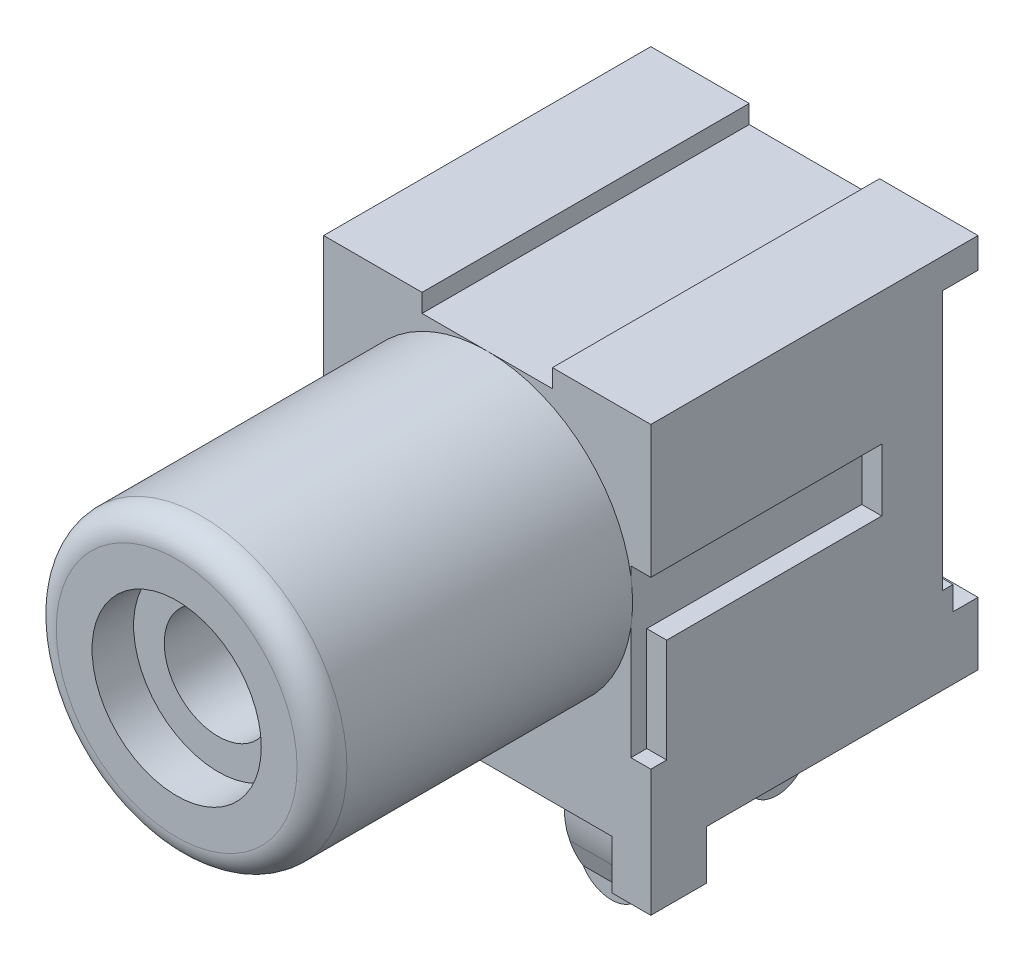
from build123d import *

# Parameters (mm, degrees)
SKETCH1_W          = 10.0076
SKETCH1_H          = 13.0048
EXTRUDE1_DEPTH     = 10.0076
SKETCH2_R          = 4.445
EXTRUDE2_DEPTH     = 9.4996
FILLET1_R          = 0.762
SKETCH3_R          = 1.64973
CUT_EXTRUDE1_DEPTH = 9.4996
CUT_EXTRUDE2_DEPTH = 0.6096
SKETCH5_W          = 1.082217623
SKETCH5_H          = 7.941923042
CUT_EXTRUDE3_DEPTH = 11.0076
SKETCH6_W          = 7.62
SKETCH6_H          = 1.4986
CUT_EXTRUDE4_DEPTH = 11.0076
SKETCH7_R          = 2.588003294
CUT_EXTRUDE5_DEPTH = 1.27
SKETCH8_W          = 3.9878
SKETCH8_H          = 0.5588
CUT_EXTRUDE6_DEPTH = 11.0076
SKETCH10_W         = 8.302680101
SKETCH10_H         = 1.4986
CUT_EXTRUDE8_DEPTH = 11.0076
SKETCH11_W         = 0.763867388
SKETCH11_H         = 0.721519404
CUT_EXTRUDE9_DEPTH = 11.0076
SKETCH12_W         = 2.0066
SKETCH12_H         = 0.381
FILLET2_R          = 0.9906
EXTRUDE3_DEPTH     = 0.254


with BuildPart() as part:
    # Sketch1 → Extrude1 (new body)
    with BuildSketch(Plane.XY):
        with Locations((0, 6.5024)):
            Rectangle(SKETCH1_W, SKETCH1_H)
    extrude(amount=-EXTRUDE1_DEPTH)

    # Sketch2 → Extrude2 (add)
    with BuildSketch(Plane.XY):
        with Locations((0, 8.001)):
            Circle(SKETCH2_R)
    extrude(amount=EXTRUDE2_DEPTH)

    # Fillet1
    fillet1_edges = [part.edges().sort_by_distance(p)[0] for p in [
        (-4.445, 8.001, 9.4996),
    ]]
    fillet(fillet1_edges, radius=FILLET1_R)

    # Sketch3 → Cut-Extrude1 (cut)
    with BuildSketch(Plane.XY.offset(9.4996)):
        with Locations((0, 8.001)):
            Circle(SKETCH3_R)
    extrude(amount=-CUT_EXTRUDE1_DEPTH, mode=Mode.SUBTRACT)

    # Sketch4 → Cut-Extrude2 (cut)
    with BuildSketch(Plane(origin=(5.0038, 0, 0), x_dir=(0, 0, -1), z_dir=(1, 0, 0))):
        Polygon((0, 8.9535), (7.063951239, 8.9535), (7.063951239, 7.0485), (0.484947525, 7.0485), (0.484947525, 3.872808147), (0, 3.872808147), align=None)
    cut_extrude2 = extrude(amount=-CUT_EXTRUDE2_DEPTH, mode=Mode.SUBTRACT)

    # Sketch5 → Cut-Extrude3 (cut, through all)
    with BuildSketch(Plane(origin=(5.0038, 0, 0), x_dir=(0, 0, -1), z_dir=(1, 0, 0))):
        with Locations((9.466491189, 8.113930335)):
            Rectangle(SKETCH5_W, SKETCH5_H)
    extrude(amount=-CUT_EXTRUDE3_DEPTH, mode=Mode.SUBTRACT)

    # Sketch6 → Cut-Extrude4 (cut, through all)
    with BuildSketch(Plane.XY):
        with Locations((0, 0.7493)):
            Rectangle(SKETCH6_W, SKETCH6_H)
    extrude(amount=-CUT_EXTRUDE4_DEPTH, mode=Mode.SUBTRACT)

    # Sketch7 → Cut-Extrude5 (cut)
    with BuildSketch(Plane.XY.offset(9.4996)):
        with Locations((0, 8.001)):
            Circle(SKETCH7_R)
    extrude(amount=-CUT_EXTRUDE5_DEPTH, mode=Mode.SUBTRACT)

    # Sketch8 → Cut-Extrude6 (cut, through all)
    with BuildSketch(Plane.XY):
        with Locations((0, 12.7254)):
            Rectangle(SKETCH8_W, SKETCH8_H)
    extrude(amount=-CUT_EXTRUDE6_DEPTH, mode=Mode.SUBTRACT)

    # Mirror1: Cut-Extrude2 across plane
    add(cut_extrude2.mirror(Plane(origin=(0, 0, 0), x_dir=(0, 0, 1), z_dir=(1, 0, 0))), mode=Mode.SUBTRACT)

    # Sketch10 → Cut-Extrude8 (cut, through all)
    with BuildSketch(Plane(origin=(5.0038, 0, 0), x_dir=(0, 0, -1), z_dir=(1, 0, 0))):
        with Locations((5.85625995, 0.7493)):
            Rectangle(SKETCH10_W, SKETCH10_H)
    extrude(amount=-CUT_EXTRUDE8_DEPTH, mode=Mode.SUBTRACT)

    # Sketch11 → Cut-Extrude9 (cut, through all)
    with BuildSketch(Plane(origin=(5.0038, 0, 0), x_dir=(0, 0, -1), z_dir=(1, 0, 0))):
        with Locations((9.625666306, 3.782209112)):
            Rectangle(SKETCH11_W, SKETCH11_H)
    extrude(amount=-CUT_EXTRUDE9_DEPTH, mode=Mode.SUBTRACT)

    # Sweep1: sweep along a path in Sketch13
    with BuildLine(Plane(origin=(0, 0, 0), x_dir=(0, 0, -1), z_dir=(1, 0, 0))) as sweep1_path:
        Line((3.9878, 1.4986), (3.9878, 0.118233573))
        ThreePointArc((3.9878, 0.118233573), (3.963359224, -0.233279995), (3.890507253, -0.578028788))
        ThreePointArc((3.890507253, -0.578028788), (3.561195264, -1.630409905), (3.70889827, -2.723175307))
        Line((3.70889827, -2.723175307), (3.9878, -3.4798))
        Line((3.9878, -3.4798), (3.9878, -3.9878))
    # Sketch12 → Sweep1 (sweep)
    with BuildSketch(Plane.XZ.offset(-1.4986)):
        with Locations((0, -3.9878)):
            Rectangle(SKETCH12_W, SKETCH12_H)
    sweep(path=sweep1_path.line, transition=Transition.RIGHT)

    # Fillet2
    fillet2_edges = [part.edges().sort_by_distance(p)[0] for p in [
        (1.0033, -3.9878, -3.9878),
        (-1.0033, -3.9878, -3.9878),
    ]]
    fillet(fillet2_edges, radius=FILLET2_R)

    # Sketch14 → Extrude3 (add, symmetric)
    with BuildSketch(Plane(origin=(0, 0, 0), x_dir=(0, 0, -1), z_dir=(1, 0, 0))):
        with BuildLine():
            Line((10.007599936, 0), (9.055129464, 0))
            Line((9.055129464, 0), (9.055129464, -1.459458075))
            Line((9.055129464, -1.459458075), (10.007599936, -1.950513398))
            Line((10.007599936, -1.950513398), (9.466255271, -3.000527083))
            ThreePointArc((9.466255271, -3.000527083), (8.363488428, -3.473928976), (7.628868664, -2.52496224))
            Line((7.628868664, -2.52496224), (7.628868664, 1.4986))
            Line((7.628868664, 1.4986), (10.007599936, 1.4986))
            Line((10.007599936, 1.4986), (10.007599936, 0))
        make_face()
    extrude(amount=EXTRUDE3_DEPTH, both=True)


solid = part.part
